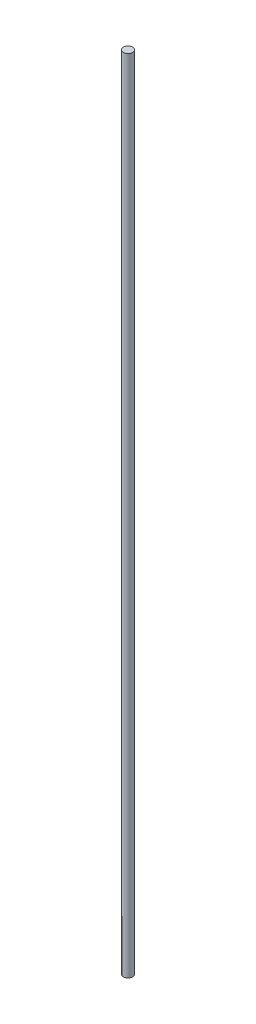
from build123d import *


with BuildPart() as part:
    # Sketch1 → Revolve1 (revolve)
    with BuildSketch(Plane.XY):
        Polygon((0, 0), (-3.175, 0), (-3.175, -552.45), (-1.5875, -552.45), (-1.5875, -542.925), (0, -542.925), align=None)
    revolve(axis=Axis((0, -542.925, 0), (0, 1, 0)))


solid = part.part
